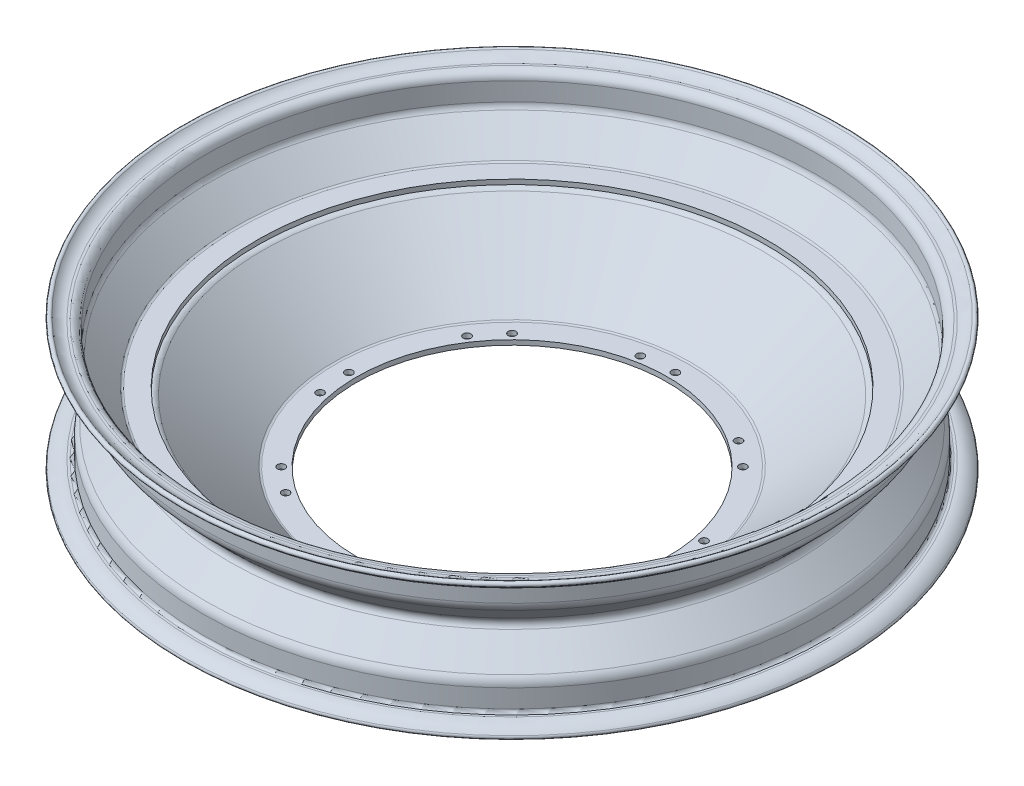
from build123d import *

# Parameters (mm, degrees)
SKETCH4_R               = 2.5
CUT_EXTRUDE3_DEPTH      = 42.595214206
CUT_EXTRUDE3_DEPTH_BACK = 49.124520078


with BuildPart() as part:
    # Sketch3 → Revolve2 (revolve)
    with BuildSketch(Plane.XY):
        with BuildLine():
            Line((-102, -48.124520078), (-116.097179263, -48.124520078))
            ThreePointArc((-116.097179263, -48.124520078), (-117.880721071, -47.803696603), (-119.440659096, -46.881448026))
            Line((-119.440659096, -46.881448026), (-165.983747962, -6.721764772))
            ThreePointArc((-165.983747962, -6.721764772), (-166.593336874, -6.361370643), (-167.290305146, -6.236))
            Line((-167.290305146, -6.236), (-180.049388931, -6.236))
            ThreePointArc((-180.049388931, -6.236), (-180.816787473, -6.396329067), (-181.463602494, -6.839314687))
            Line((-181.463602494, -6.839314687), (-198.251490932, -23.609067138))
            ThreePointArc((-198.251490932, -23.609067138), (-199.351899333, -25.212361847), (-199.739183475, -27.118001784))
            Line((-199.739183475, -27.118001784), (-199.739183475, -39.117999668))
            ThreePointArc((-199.739183475, -39.117999668), (-201.238210969, -42.736972174), (-204.857183475, -44.235999668))
            Line((-204.857183475, -44.235999668), (-206.357183497, -44.235999668))
            ThreePointArc((-206.357183497, -44.235999668), (-210.160078428, -45.041291982), (-213.310139828, -47.318926446))
            ThreePointArc((-213.310139828, -47.318926446), (-215.512219762, -47.4275817), (-215.620875016, -45.225501766))
            ThreePointArc((-215.620875016, -45.225501766), (-211.423926876, -42.190921638), (-206.357183475, -41.117999668))
            Line((-206.357183475, -41.117999668), (-204.857183475, -41.117999668))
            ThreePointArc((-204.857183475, -41.117999668), (-203.442969913, -40.53221323), (-202.857183475, -39.117999668))
            Line((-202.857183475, -39.117999668), (-202.857183475, -27.118001784))
            ThreePointArc((-202.857183475, -27.118001784), (-202.22255126, -23.995282756), (-200.41934243, -21.368008487))
            Line((-200.41934243, -21.368008487), (-185.35258838, -6.301254436))
            ThreePointArc((-185.35258838, -6.301254436), (-184.03404122, -3.118), (-185.35258838, 0.065254437))
            Line((-185.35258838, 0.065254437), (-200.41934243, 15.132008487))
            ThreePointArc((-200.41934243, 15.132008487), (-202.22255126, 17.759282757), (-202.857183476, 20.882001784))
            Line((-202.857183476, 20.882001784), (-202.857183476, 32.881999668))
            ThreePointArc((-202.857183476, 32.881999668), (-203.442969914, 34.296213231), (-204.857183476, 34.881999668))
            Line((-204.857183476, 34.881999668), (-206.357183476, 34.881999668))
            ThreePointArc((-206.357183476, 34.881999668), (-211.423926877, 35.954921638), (-215.620875017, 38.989501766))
            ThreePointArc((-215.620875017, 38.989501766), (-215.512219763, 41.1915817), (-213.310139829, 41.082926446))
            ThreePointArc((-213.310139829, 41.082926446), (-210.16007843, 38.805291983), (-206.357183499, 37.999999668))
            Line((-206.357183499, 37.999999668), (-204.857183476, 37.999999668))
            ThreePointArc((-204.857183476, 37.999999668), (-201.23821097, 36.500972175), (-199.739183476, 32.881999668))
            Line((-199.739183476, 32.881999668), (-199.739183476, 20.882001784))
            ThreePointArc((-199.739183476, 20.882001784), (-199.351809516, 18.976419568), (-198.251353913, 17.373204164))
            Line((-198.251353913, 17.373204164), (-181.463769341, 0.585619592))
            ThreePointArc((-181.463769341, 0.585619592), (-180.814826345, 0.152131935), (-180.049388931, 0))
            Line((-180.049388931, 0), (-167.290305146, 0))
            Line((-167.290305146, 0), (-167.290305146, -3.118))
            ThreePointArc((-167.290305146, -3.118), (-165.506763338, -3.438823474), (-163.946825313, -4.361072052))
            Line((-163.946825313, -4.361072052), (-117.403736447, -44.520755305))
            ThreePointArc((-117.403736447, -44.520755305), (-116.794147535, -44.881149435), (-116.097179263, -45.006520077))
            Line((-116.097179263, -45.006520077), (-102, -45.006520077))
            Line((-102, -45.006520077), (-102, -48.124520078))
        make_face()
    revolve(axis=Axis((0, 240.888952165, 0), (0, -1, 0)))

    # Sketch4 → Cut-Extrude3 (cut, two sides)
    with BuildSketch(Plane(origin=(0, 0, 0), x_dir=(1, 0, 0), z_dir=(0, 1, 0))) as cut_extrude3_sk:
        with Locations((0, 107)):
            Circle(SKETCH4_R)
        with Locations((-3884.181572475, -9484.24383099)):
            Circle(SKETCH4_R)
        with Locations((-13412.746254639, -13519.746254639)):
            Circle(SKETCH4_R)
        with Locations((-23003.990085629, -9635.564682164)):
            Circle(SKETCH4_R)
        with Locations((-27039.492509279, -107)):
            Circle(SKETCH4_R)
        with Locations((-23155.310936803, 9484.24383099)):
            Circle(SKETCH4_R)
        with Locations((-13626.746254639, 13519.746254639)):
            Circle(SKETCH4_R)
        with Locations((-4035.502423649, 9635.564682164)):
            Circle(SKETCH4_R)
        with Locations((-20.874664456, 104.944025003)):
            Circle(SKETCH4_R)
        with Locations((-3900.395983129, -9470.93700806)):
            Circle(SKETCH4_R)
        with Locations((-13414.802229636, -13498.871590184)):
            Circle(SKETCH4_R)
        with Locations((-22990.6832627, -9619.35027151)):
            Circle(SKETCH4_R)
        with Locations((-27018.617844823, -104.944025003)):
            Circle(SKETCH4_R)
        with Locations((-23139.096526149, 9470.93700806)):
            Circle(SKETCH4_R)
        with Locations((-13624.690279642, 13498.871590184)):
            Circle(SKETCH4_R)
        with Locations((-4048.809246579, 9619.35027151)):
            Circle(SKETCH4_R)
        with Locations((75.660425587, 75.660425587)):
            Circle(SKETCH4_R)
        with Locations((59.446014933, 88.967248516)):
            Circle(SKETCH4_R)
        with Locations((107, 0)):
            Circle(SKETCH4_R)
        with Locations((104.944025003, 20.874664456)):
            Circle(SKETCH4_R)
        with Locations((75.660425587, -75.660425587)):
            Circle(SKETCH4_R)
        with Locations((88.967248516, -59.446014933)):
            Circle(SKETCH4_R)
        with Locations((0, -107)):
            Circle(SKETCH4_R)
        with Locations((20.874664456, -104.944025003)):
            Circle(SKETCH4_R)
        with Locations((-75.660425587, -75.660425587)):
            Circle(SKETCH4_R)
        with Locations((-59.446014933, -88.967248516)):
            Circle(SKETCH4_R)
        with Locations((-107, 0)):
            Circle(SKETCH4_R)
        with Locations((-104.944025003, -20.874664456)):
            Circle(SKETCH4_R)
        with Locations((-75.660425587, 75.660425587)):
            Circle(SKETCH4_R)
        with Locations((-88.967248516, 59.446014933)):
            Circle(SKETCH4_R)
    extrude(amount=CUT_EXTRUDE3_DEPTH, mode=Mode.SUBTRACT)
    extrude(cut_extrude3_sk.sketch, amount=-CUT_EXTRUDE3_DEPTH_BACK, mode=Mode.SUBTRACT)


solid = part.part
